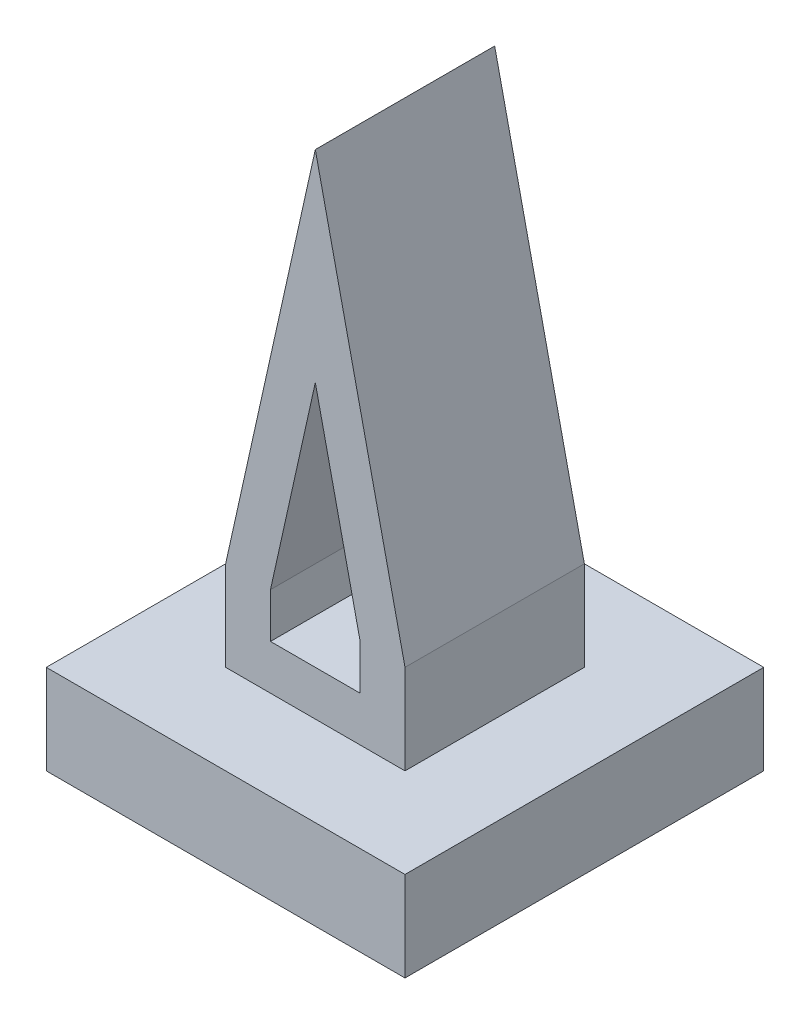
from build123d import *

# Parameters (mm, degrees)
SKETCH1_W      = 80
SKETCH1_H      = 80
EXTRUDE1_DEPTH = 20
SKETCH2_W      = 40
SKETCH2_H      = 40
EXTRUDE2_DEPTH = 110
EXTRUDE3_DEPTH = 110


with BuildPart() as part:
    # Sketch1 → Extrude1 (new body)
    with BuildSketch(Plane(origin=(0, 0, 0), x_dir=(1, 0, 0), z_dir=(0, 1, 0))):
        with Locations((-40, 40)):
            Rectangle(SKETCH1_W, SKETCH1_H)
    extrude(amount=EXTRUDE1_DEPTH)

    # Sketch2 → Extrude2 (add)
    with BuildSketch(Plane(origin=(0, 20, 0), x_dir=(1, 0, 0), z_dir=(0, 1, 0))):
        with Locations((-40, 40)):
            Rectangle(SKETCH2_W, SKETCH2_H)
    extrude(amount=EXTRUDE2_DEPTH)

    # Sketch3 → Extrude3 (cut)
    with BuildSketch(Plane.XY.offset(-20)):
        Polygon((-60, 40), (-40, 130), (-60, 130), align=None)
        Polygon((-40, 130), (-20, 40), (-20, 130), align=None)
        Polygon((-50, 40), (-40, 85), (-30, 40), (-30, 30), (-50, 30), align=None)
    extrude(amount=-EXTRUDE3_DEPTH, mode=Mode.SUBTRACT)


solid = part.part
